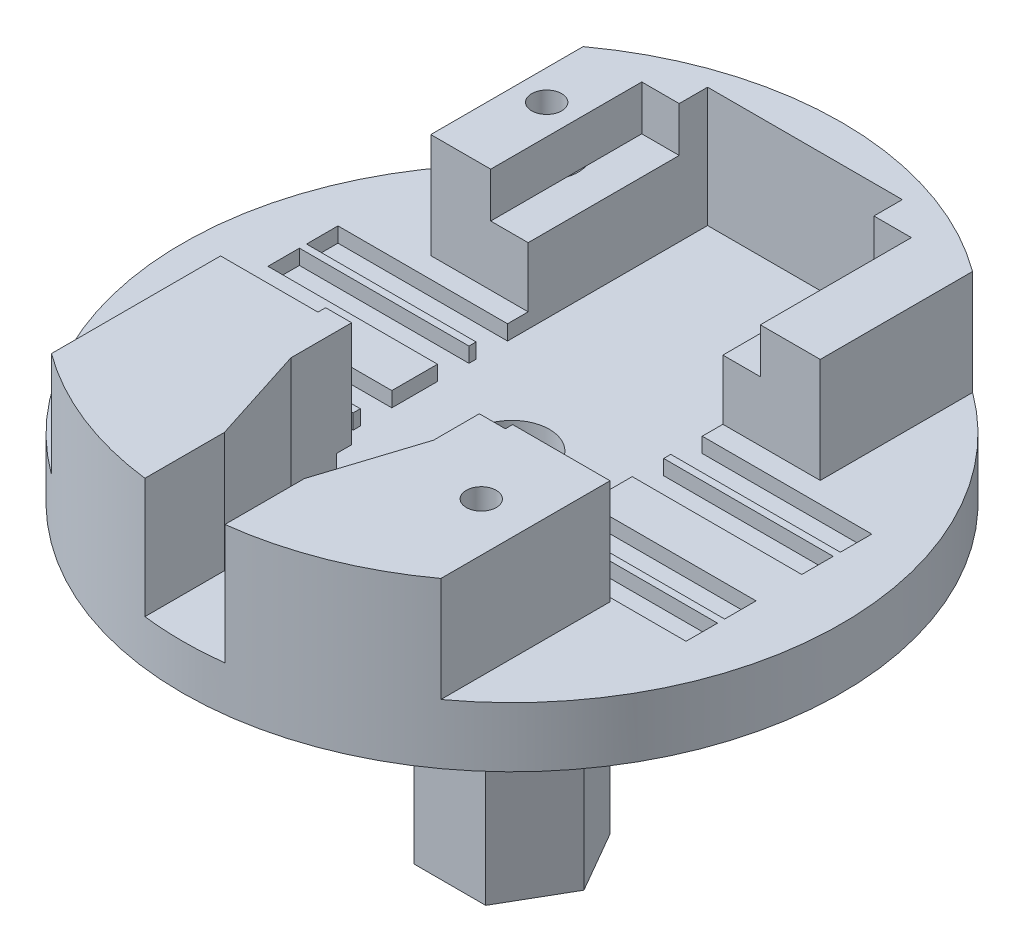
from build123d import *

# Parameters (mm, degrees)
BOSS_EXTRUDE1_DEPTH      = 9
BOSS_EXTRUDE1_DEPTH_BACK = 2
SKETCH1_R                = 22
SKETCH6_R                = 21
SKETCH6_R_2              = 12.5
CUT_EXTRUDE5_DEPTH       = 1
SKETCH7_R                = 8.5
BOSS_EXTRUDE2_DEPTH      = 40
CUT_EXTRUDE6_DEPTH       = 51.675437837
CUT_EXTRUDE6_DEPTH_BACK  = 51.675437837
SKETCH8_R                = 1.5
CUT_EXTRUDE7_DEPTH       = 7
SKETCH17_R               = 2.496785081
CUT_EXTRUDE14_DEPTH      = 62
SKETCH29_W               = 18
SKETCH29_H               = 24.118038922
CUT_EXTRUDE19_DEPTH      = 3
SKETCH30_W               = 2.5
SKETCH30_H               = 14
CUT_EXTRUDE20_DEPTH      = 6
BOSS_EXTRUDE4_DEPTH      = 2
BOSS_EXTRUDE4_DEPTH_BACK = 2
SKETCH35_R               = 9.1
SKETCH35_R_2             = 8.5
CUT_EXTRUDE28_DEPTH      = 1.5
CUT_EXTRUDE28_DEPTH_BACK = 1.5
SKETCH36_R               = 8.5
SKETCH36_R_2             = 8.3
CUT_EXTRUDE30_DEPTH      = 1.5
CUT_EXTRUDE30_DEPTH_BACK = 1.5
SKETCH39_R               = 8.5
SKETCH39_R_2             = 8.3
CUT_EXTRUDE31_DEPTH      = 1.5
CUT_EXTRUDE31_DEPTH_BACK = 1.5
SKETCH40_R               = 8.5
SKETCH40_R_2             = 8.3
CUT_EXTRUDE32_DEPTH      = 1.5
CUT_EXTRUDE32_DEPTH_BACK = 1.5
SKETCH41_R               = 8.5
SKETCH41_R_2             = 8.35
CUT_EXTRUDE33_DEPTH      = 1.5
CUT_EXTRUDE33_DEPTH_BACK = 1.5
SKETCH42_R               = 8.5
SKETCH42_R_2             = 8.3
CUT_EXTRUDE34_DEPTH      = 1.5
CUT_EXTRUDE34_DEPTH_BACK = 1.5
SKETCH43_R               = 8.5
SKETCH43_R_2             = 8.3
CUT_EXTRUDE35_DEPTH      = 53.268537381
CUT_EXTRUDE35_DEPTH_BACK = 53.268537381
SKETCH44_R               = 1
CUT_EXTRUDE36_DEPTH      = 53.268537462
CUT_EXTRUDE36_DEPTH_BACK = 53.268537462
SKETCH45_R               = 1
CUT_EXTRUDE37_DEPTH      = 53.268537462
CUT_EXTRUDE37_DEPTH_BACK = 53.268537462
SKETCH46_R               = 1
SKETCH47_W               = 27.732128476
SKETCH47_H               = 14.033639909
CUT_EXTRUDE38_DEPTH      = 7
CUT_EXTRUDE39_DEPTH      = 8
SKETCH48_R               = 1
CUT_EXTRUDE40_DEPTH      = 9
SKETCH50_R               = 6.388253867
BOSS_EXTRUDE5_DEPTH      = 2
SKETCH49_R               = 2.1
CUT_EXTRUDE42_DEPTH      = 7
SKETCH51_W               = 35.63730279
SKETCH51_H               = 2.1
CUT_EXTRUDE43_DEPTH      = 1
SKETCH53_R               = 9.1
CUT_EXTRUDE45_DEPTH      = 40
SKETCH55_W               = 1.737607108
SKETCH55_H               = 7.054348591
BOSS_EXTRUDE6_DEPTH      = 1
BOSS_EXTRUDE9_DEPTH      = 20
BOSS_EXTRUDE9_DEPTH_BACK = 2


with BuildPart() as part:
    # Sketch1 → Boss-Extrude1 (new, two sides: drawn at the far end of the back side and taken through both)
    with BuildSketch(Plane(origin=(0, 0, 0), x_dir=(1, 0, 0), z_dir=(0, 1, 0)).offset(-BOSS_EXTRUDE1_DEPTH_BACK)):
        Circle(SKETCH1_R)
    extrude(amount=BOSS_EXTRUDE1_DEPTH + BOSS_EXTRUDE1_DEPTH_BACK)

    # Sketch6 → Cut-Extrude5 (cut)
    with BuildSketch(Plane(origin=(0, -2, 0), x_dir=(-1, 0, 0), z_dir=(0, -1, 0))):
        Circle(SKETCH6_R)
        Circle(SKETCH6_R_2, mode=Mode.SUBTRACT)
    extrude(amount=-CUT_EXTRUDE5_DEPTH, mode=Mode.SUBTRACT)

    # Sketch7 → Boss-Extrude2 (add)
    with BuildSketch(Plane(origin=(0, -2, 0), x_dir=(-1, 0, 0), z_dir=(0, -1, 0))):
        Circle(SKETCH7_R)
    extrude(amount=BOSS_EXTRUDE2_DEPTH)

    # Sketch8 → Cut-Extrude6 (cut, two sides: drawn at the far end of the back side and taken through both)
    with BuildSketch(Plane(origin=(0, -2, 0), x_dir=(-1, 0, 0), z_dir=(0, -1, 0)).offset(-CUT_EXTRUDE6_DEPTH_BACK)):
        Circle(SKETCH8_R)
    extrude(amount=CUT_EXTRUDE6_DEPTH + CUT_EXTRUDE6_DEPTH_BACK, mode=Mode.SUBTRACT)

    # Sketch9 → Cut-Extrude7 (cut)
    with BuildSketch(Plane(origin=(0, 9, 0), x_dir=(1, 0, 0), z_dir=(0, 1, 0))):
        with BuildLine():
            Line((-13.000713231, -20.359249211), (-13.000713231, 20.359249211))
            ThreePointArc((-13.000713231, 20.359249211), (-24.156108398, 0), (-13.000713231, -20.359249211))
        make_face()
        with BuildLine():
            Line((13, -20.359704638), (13, 20.359704638))
            ThreePointArc((13, 20.359704638), (24.156108398, 0), (13, -20.359704638))
        make_face()
    extrude(amount=-CUT_EXTRUDE7_DEPTH, mode=Mode.SUBTRACT)

    # Sketch17 → Cut-Extrude14 (cut)
    with BuildSketch(Plane(origin=(0, -42, 0), x_dir=(-1, 0, 0), z_dir=(0, -1, 0))):
        Circle(SKETCH17_R)
    extrude(amount=-CUT_EXTRUDE14_DEPTH, mode=Mode.SUBTRACT)

    # Sketch29 → Cut-Extrude19 (cut)
    with BuildSketch(Plane(origin=(0, 9, 0), x_dir=(1, 0, 0), z_dir=(0, 1, 0))):
        with Locations((0, 5.603215798)):
            Rectangle(SKETCH29_W, SKETCH29_H)
    extrude(amount=-CUT_EXTRUDE19_DEPTH, mode=Mode.SUBTRACT)

    # Sketch30 → Cut-Extrude20 (cut)
    with BuildSketch(Plane(origin=(0, 9, 0), x_dir=(1, 0, 0), z_dir=(0, 1, 0))):
        with Locations((6.752146467, 0.544196337)):
            Rectangle(SKETCH30_W, SKETCH30_H)
        with Locations((-6.752146467, 0.544196337)):
            Rectangle(SKETCH30_W, SKETCH30_H)
    extrude(amount=-CUT_EXTRUDE20_DEPTH, mode=Mode.SUBTRACT)

    # Sketch35 → Boss-Extrude4 (add, two sides: drawn at the far end of the back side and taken through both)
    with BuildSketch(Plane(origin=(0, -6.5, 0), x_dir=(1, 0, 0), z_dir=(0, 1, 0)).offset(-BOSS_EXTRUDE4_DEPTH_BACK)):
        Circle(SKETCH35_R)
        Circle(SKETCH35_R_2, mode=Mode.SUBTRACT)
    extrude(amount=BOSS_EXTRUDE4_DEPTH + BOSS_EXTRUDE4_DEPTH_BACK)

    # Sketch36 → Cut-Extrude28 (cut, two sides: drawn at the far end of the back side and taken through both)
    with BuildSketch(Plane(origin=(0, -17, 0), x_dir=(1, 0, 0), z_dir=(0, 1, 0)).offset(-CUT_EXTRUDE28_DEPTH_BACK)):
        Circle(SKETCH36_R)
        Circle(SKETCH36_R_2, mode=Mode.SUBTRACT)
    extrude(amount=CUT_EXTRUDE28_DEPTH + CUT_EXTRUDE28_DEPTH_BACK, mode=Mode.SUBTRACT)

    # Sketch39 → Cut-Extrude30 (cut, two sides: drawn at the far end of the back side and taken through both)
    with BuildSketch(Plane(origin=(0, -21, 0), x_dir=(1, 0, 0), z_dir=(0, 1, 0)).offset(-CUT_EXTRUDE30_DEPTH_BACK)):
        Circle(SKETCH39_R)
        Circle(SKETCH39_R_2, mode=Mode.SUBTRACT)
    extrude(amount=CUT_EXTRUDE30_DEPTH + CUT_EXTRUDE30_DEPTH_BACK, mode=Mode.SUBTRACT)

    # Sketch40 → Cut-Extrude31 (cut, two sides: drawn at the far end of the back side and taken through both)
    with BuildSketch(Plane(origin=(0, -25, 0), x_dir=(1, 0, 0), z_dir=(0, 1, 0)).offset(-CUT_EXTRUDE31_DEPTH_BACK)):
        Circle(SKETCH40_R)
        Circle(SKETCH40_R_2, mode=Mode.SUBTRACT)
    extrude(amount=CUT_EXTRUDE31_DEPTH + CUT_EXTRUDE31_DEPTH_BACK, mode=Mode.SUBTRACT)

    # Sketch41 → Cut-Extrude32 (cut, two sides: drawn at the far end of the back side and taken through both)
    with BuildSketch(Plane(origin=(0, -29, 0), x_dir=(1, 0, 0), z_dir=(0, 1, 0)).offset(-CUT_EXTRUDE32_DEPTH_BACK)):
        Circle(SKETCH41_R)
        Circle(SKETCH41_R_2, mode=Mode.SUBTRACT)
    extrude(amount=CUT_EXTRUDE32_DEPTH + CUT_EXTRUDE32_DEPTH_BACK, mode=Mode.SUBTRACT)

    # Sketch42 → Cut-Extrude33 (cut, two sides: drawn at the far end of the back side and taken through both)
    with BuildSketch(Plane(origin=(0, -33, 0), x_dir=(1, 0, 0), z_dir=(0, 1, 0)).offset(-CUT_EXTRUDE33_DEPTH_BACK)):
        Circle(SKETCH42_R)
        Circle(SKETCH42_R_2, mode=Mode.SUBTRACT)
    extrude(amount=CUT_EXTRUDE33_DEPTH + CUT_EXTRUDE33_DEPTH_BACK, mode=Mode.SUBTRACT)

    # Sketch43 → Cut-Extrude34 (cut, two sides: drawn at the far end of the back side and taken through both)
    with BuildSketch(Plane(origin=(0, -37, 0), x_dir=(1, 0, 0), z_dir=(0, 1, 0)).offset(-CUT_EXTRUDE34_DEPTH_BACK)):
        Circle(SKETCH43_R)
        Circle(SKETCH43_R_2, mode=Mode.SUBTRACT)
    extrude(amount=CUT_EXTRUDE34_DEPTH + CUT_EXTRUDE34_DEPTH_BACK, mode=Mode.SUBTRACT)

    # Sketch44 → Cut-Extrude35 (cut, two sides: drawn at the far end of the back side and taken through both)
    with BuildSketch(Plane.XY.offset(-CUT_EXTRUDE35_DEPTH_BACK)):
        with Locations((0, -16.975647938)):
            Circle(SKETCH44_R)
        with Locations((0, -29.042179734)):
            Circle(SKETCH44_R)
    extrude(amount=CUT_EXTRUDE35_DEPTH + CUT_EXTRUDE35_DEPTH_BACK, mode=Mode.SUBTRACT)

    # Sketch45 → Cut-Extrude36 (cut, two sides: drawn at the far end of the back side and taken through both)
    with BuildSketch(Plane(origin=(0, 0, 0), x_dir=(0, 1, 0), z_dir=(0.8660254037844398, 0, 0.499999999999998)).offset(-CUT_EXTRUDE36_DEPTH_BACK)):
        with Locations((-21.101513607, 0)):
            Circle(SKETCH45_R)
        with Locations((-33.049455879, 0)):
            Circle(SKETCH45_R)
    extrude(amount=CUT_EXTRUDE36_DEPTH + CUT_EXTRUDE36_DEPTH_BACK, mode=Mode.SUBTRACT)

    # Sketch46 → Cut-Extrude37 (cut, two sides: drawn at the far end of the back side and taken through both)
    with BuildSketch(Plane(origin=(0, 0, 0), x_dir=(0, 1, 0), z_dir=(0.8660254037844364, 0, -0.500000000000004)).offset(-CUT_EXTRUDE37_DEPTH_BACK)):
        with Locations((-24.961001523, 0)):
            Circle(SKETCH46_R)
        with Locations((-37.130366549, 0)):
            Circle(SKETCH46_R)
    extrude(amount=CUT_EXTRUDE37_DEPTH + CUT_EXTRUDE37_DEPTH_BACK, mode=Mode.SUBTRACT)

    # Sketch47 → Cut-Extrude38 (cut)
    with BuildSketch(Plane(origin=(0, 9, 0), x_dir=(1, 0, 0), z_dir=(0, 1, 0))):
        with Locations((-0.011675811, 0.561016292)):
            Rectangle(SKETCH47_W, SKETCH47_H)
    extrude(amount=-CUT_EXTRUDE38_DEPTH, mode=Mode.SUBTRACT)

    # Sketch23 → Cut-Extrude39 (cut)
    with BuildSketch(Plane(origin=(0, 9, 0), x_dir=(1, 0, 0), z_dir=(0, 1, 0))):
        with BuildLine():
            Line((-2.670420152, -16.85816067), (-2.670420152, -16.530371213))
            Line((-2.670420152, -16.530371213), (-4.762392892, -10))
            Line((-4.762392892, -10), (-4.762392892, -6.943148259))
            Line((-4.762392892, -6.943148259), (-6.5, -6.943148259))
            Line((-6.5, -6.943148259), (-6.5, 19.556851741))
            Line((-6.5, 19.556851741), (6.5, 19.556851741))
            Line((6.5, 19.556851741), (6.5, -6.943148259))
            Line((6.5, -6.943148259), (4.762392892, -6.943148259))
            Line((4.762392892, -6.943148259), (4.762392892, -10))
            Line((4.762392892, -10), (2.670420152, -16.530371213))
            Line((2.670420152, -16.530371213), (2.670420152, -16.85816067))
            Line((2.670420152, -16.85816067), (2.670420152, -21.837327131))
            ThreePointArc((2.670420152, -21.837327131), (1.836835043, -21.92318492), (1.000584871, -21.977234355))
            Line((1.000584871, -21.977234355), (0, -25.25))
            Line((0, -25.25), (-1.000584871, -21.977234355))
            ThreePointArc((-1.000584871, -21.977234355), (-1.836835043, -21.92318492), (-2.670420152, -21.837327131))
            Line((-2.670420152, -21.837327131), (-2.670420152, -16.85816067))
        make_face()
    extrude(amount=-CUT_EXTRUDE39_DEPTH, mode=Mode.SUBTRACT)

    # Sketch48 → Cut-Extrude40 (cut)
    with BuildSketch(Plane(origin=(0, 9, 0), x_dir=(1, 0, 0), z_dir=(0, 1, 0))):
        with Locations((-11, 13.315197565)):
            Circle(SKETCH48_R)
        with Locations((9.750356615, -11.802538605)):
            Circle(SKETCH48_R)
    extrude(amount=-CUT_EXTRUDE40_DEPTH, mode=Mode.SUBTRACT)

    # Sketch50 → Boss-Extrude5 (add)
    with BuildSketch(Plane.XZ.offset(42)):
        Circle(SKETCH50_R)
        Polygon((-4.989659815, -0.000576747), (-2.49433043, -4.321460529), (2.495329385, -4.320883782), (4.989659815, 0.000576747), (2.49433043, 4.321460529), (-2.495329385, 4.320883782), align=None, mode=Mode.SUBTRACT)
    extrude(amount=-BOSS_EXTRUDE5_DEPTH)

    # Sketch49 → Cut-Extrude42 (cut)
    with BuildSketch(Plane.XZ.offset(1)):
        with Locations((-11, -13.315197565)):
            Circle(SKETCH49_R)
        with Locations((9.750356615, 11.802538605)):
            Circle(SKETCH49_R)
    extrude(amount=-CUT_EXTRUDE42_DEPTH, mode=Mode.SUBTRACT)

    # Sketch51 → Cut-Extrude43 (cut)
    with BuildSketch(Plane(origin=(0, 2, 0), x_dir=(1, 0, 0), z_dir=(0, 1, 0))):
        with Locations((0, 5.15)):
            Rectangle(SKETCH51_W, SKETCH51_H)
        with Locations((0, 2.575)):
            Rectangle(SKETCH51_W, SKETCH51_H)
        with Locations((0, -2.575)):
            Rectangle(SKETCH51_W, SKETCH51_H)
        with Locations((0, -5.15)):
            Rectangle(SKETCH51_W, SKETCH51_H)
    extrude(amount=-CUT_EXTRUDE43_DEPTH, mode=Mode.SUBTRACT)

    # Sketch53 → Cut-Extrude45 (cut)
    with BuildSketch(Plane.XZ.offset(42)):
        Circle(SKETCH53_R)
    extrude(amount=-CUT_EXTRUDE45_DEPTH, mode=Mode.SUBTRACT)

    # Sketch55 → Boss-Extrude6 (add)
    with BuildSketch(Plane(origin=(0, 0, 6.943148259), x_dir=(-1, 0, 0), z_dir=(0, 0, -1))):
        Polygon((-4.762392892, 8), (-6.167287474, 8), (-6.167287474, 6), (-6.5, 6), (-6.5, 1.945651409), (-4.762392892, 1.945651409), align=None)
        with Locations((5.631196446, 5.472825704)):
            Rectangle(SKETCH55_W, SKETCH55_H)
    extrude(amount=BOSS_EXTRUDE6_DEPTH)


with BuildPart() as body_2:
    # Sketch56 → Boss-Extrude9 (new, two sides: drawn at the far end of the back side and taken through both)
    with BuildSketch(Plane.XZ.offset(2).offset(-BOSS_EXTRUDE9_DEPTH_BACK)):
        Polygon((2.399519492, 4.157199323), (-2.400480476, 4.156644498), (-4.799999968, -0.000554824), (-2.399519492, -4.157199323), (2.400480476, -4.156644498), (4.799999968, 0.000554824), align=None)
    extrude(amount=BOSS_EXTRUDE9_DEPTH + BOSS_EXTRUDE9_DEPTH_BACK)


solid = Compound([part.part, body_2.part])
